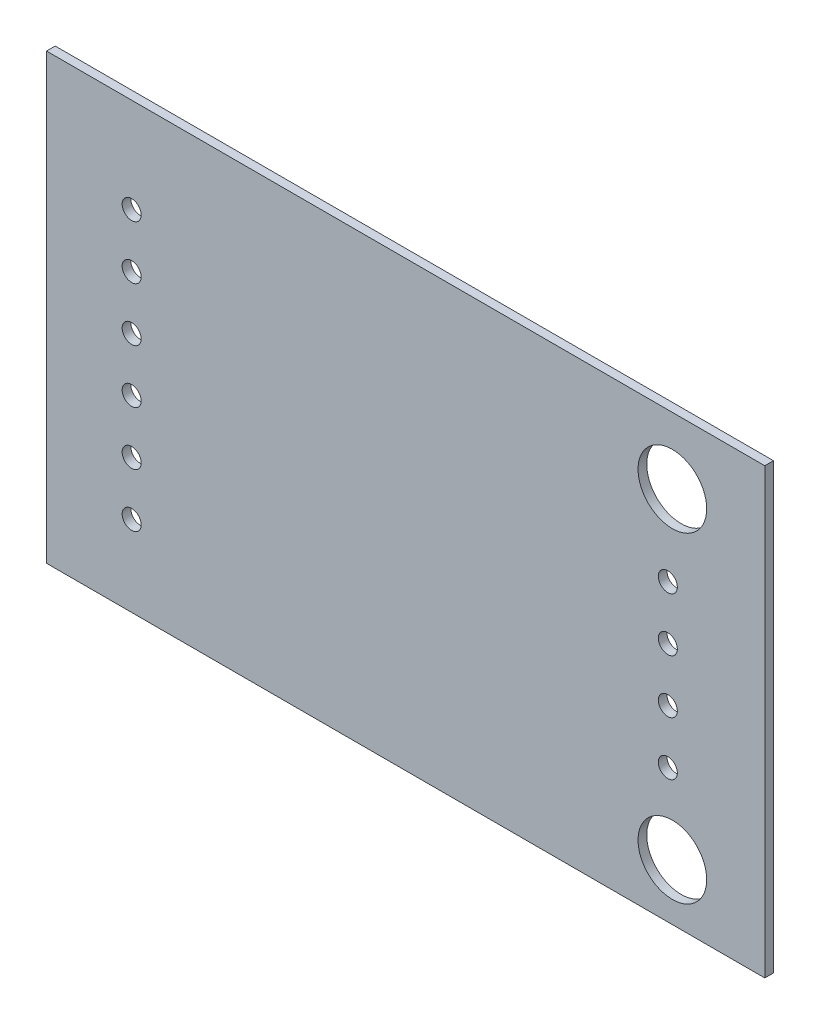
from build123d import *

# Parameters (mm, degrees)
ESBO_O1_W                = 34.00000312
ESBO_O1_H                = 21.00000372
ESBO_O1_R                = 0.4499991
RESSALTO_EXTRUS_O1_DEPTH = 0.41148
ESBO_O2_R                = 1.625
CORTE_EXTRUS_O1_DEPTH    = 1.41148


with BuildPart() as part:
    # Esboço1 → Ressalto-extrusão1 (new body)
    with BuildSketch(Plane.XY.offset(0.41148)):
        with Locations((17.00001426, 10.50001456)):
            Rectangle(ESBO_O1_W, ESBO_O1_H)
        with Locations((29.409885994, 11.411813558)):
            Circle(ESBO_O1_R, mode=Mode.SUBTRACT)
        with Locations((29.409885994, 8.871813558)):
            Circle(ESBO_O1_R, mode=Mode.SUBTRACT)
        with Locations((29.409885994, 13.951813558)):
            Circle(ESBO_O1_R, mode=Mode.SUBTRACT)
        with Locations((29.409885994, 6.331813558)):
            Circle(ESBO_O1_R, mode=Mode.SUBTRACT)
        with Locations((4.030717622, 3.815479677)):
            Circle(ESBO_O1_R, mode=Mode.SUBTRACT)
        with Locations((4.030717622, 13.975479677)):
            Circle(ESBO_O1_R, mode=Mode.SUBTRACT)
        with Locations((4.030717622, 11.435479677)):
            Circle(ESBO_O1_R, mode=Mode.SUBTRACT)
        with Locations((4.030717622, 16.515479677)):
            Circle(ESBO_O1_R, mode=Mode.SUBTRACT)
        with Locations((4.030717622, 6.355479677)):
            Circle(ESBO_O1_R, mode=Mode.SUBTRACT)
        with Locations((4.030717622, 8.895479677)):
            Circle(ESBO_O1_R, mode=Mode.SUBTRACT)
    extrude(amount=-RESSALTO_EXTRUS_O1_DEPTH)

    # Esboço2 → Corte-extrusão1 (cut, through all)
    with BuildSketch(Plane.XY.offset(0.41148)):
        with Locations((29.625048643, 17.858037309)):
            Circle(ESBO_O2_R)
        with Locations((29.625048643, 2.658236219)):
            Circle(ESBO_O2_R)
    extrude(amount=-CORTE_EXTRUS_O1_DEPTH, mode=Mode.SUBTRACT)


solid = part.part
